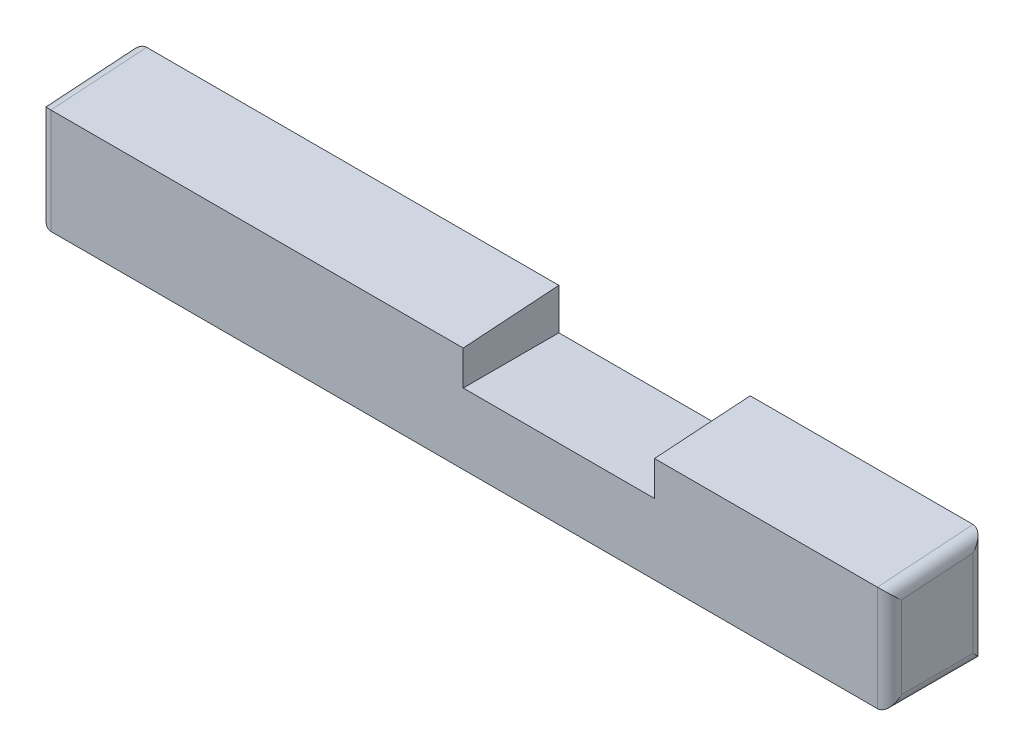
from build123d import *

# Parameters (mm, degrees)
BOSS_EXTRUDE3_DEPTH = 9.25
SKETCH5_W           = 4
SKETCH5_H           = 0.86
CUT_EXTRUDE1_DEPTH  = 2
SKETCH6_W           = 3.5
SKETCH6_H           = 0.5
BOSS_EXTRUDE4_DEPTH = 0.5
SKETCH7_W           = 0.72
SKETCH7_H           = 2.3359
CUT_EXTRUDE2_DEPTH  = 2
FILLET1_R           = 0.25
FILLET2_R           = 0.1


with BuildPart() as part:
    # Sketch1 → Boss-Extrude3 (new body, symmetric)
    with BuildSketch(Plane(origin=(0, 0, 0), x_dir=(0, 0, -1), z_dir=(1, 0, 0))):
        Polygon((-0.122813016, -2.026219673), (-0.122813016, 0.173780327), (1.877186984, 0.309680327), (1.877186984, -2.026219673), align=None)
    extrude(amount=BOSS_EXTRUDE3_DEPTH, both=True)

    # Sketch5 → Cut-Extrude1 (cut)
    with BuildSketch(Plane(origin=(0, 0, -1.877186984), x_dir=(-1, 0, 0), z_dir=(0, 0, -1))):
        with Locations((-2.34, -0.120319673)):
            Rectangle(SKETCH5_W, SKETCH5_H)
    extrude(amount=-CUT_EXTRUDE1_DEPTH, mode=Mode.SUBTRACT)

    # Sketch6 → Boss-Extrude4 (add)
    with BuildSketch(Plane.XZ.offset(2.026219673)):
        with Locations((0.34, -0.877186984)):
            Rectangle(SKETCH6_W, SKETCH6_H)
    extrude(amount=BOSS_EXTRUDE4_DEPTH)

    # Sketch7 → Cut-Extrude2 (cut)
    with BuildSketch(Plane(origin=(0, 0, -1.877186984), x_dir=(-1, 0, 0), z_dir=(0, 0, -1))):
        with Locations((8.89, -0.858269673)):
            Rectangle(SKETCH7_W, SKETCH7_H)
    extrude(amount=-CUT_EXTRUDE2_DEPTH, mode=Mode.SUBTRACT)

    # Fillet1
    fillet1_edges = [part.edges().sort_by_distance(p)[0] for p in [
        (9.25, -0.858269673, -1.877186984),
        (9.25, -2.026219673, -0.877186984),
        (9.25, -0.926219673, 0.122813016),
        (-8.53, 0.241730327, -0.877186984),
        (-8.53, -0.926219673, 0.122813016),
        (-8.53, -2.026219673, -0.877186984),
        (-8.53, -0.858269673, -1.877186984),
        (9.25, 0.241730327, -0.877186984),
    ]]
    fillet(fillet1_edges, radius=FILLET1_R)

    # Fillet2
    fillet2_edges = [part.edges().sort_by_distance(p)[0] for p in [
        (-1.41, -2.526219673, -0.877186984),
        (2.09, -2.526219673, -0.877186984),
    ]]
    fillet(fillet2_edges, radius=FILLET2_R)


solid = part.part
